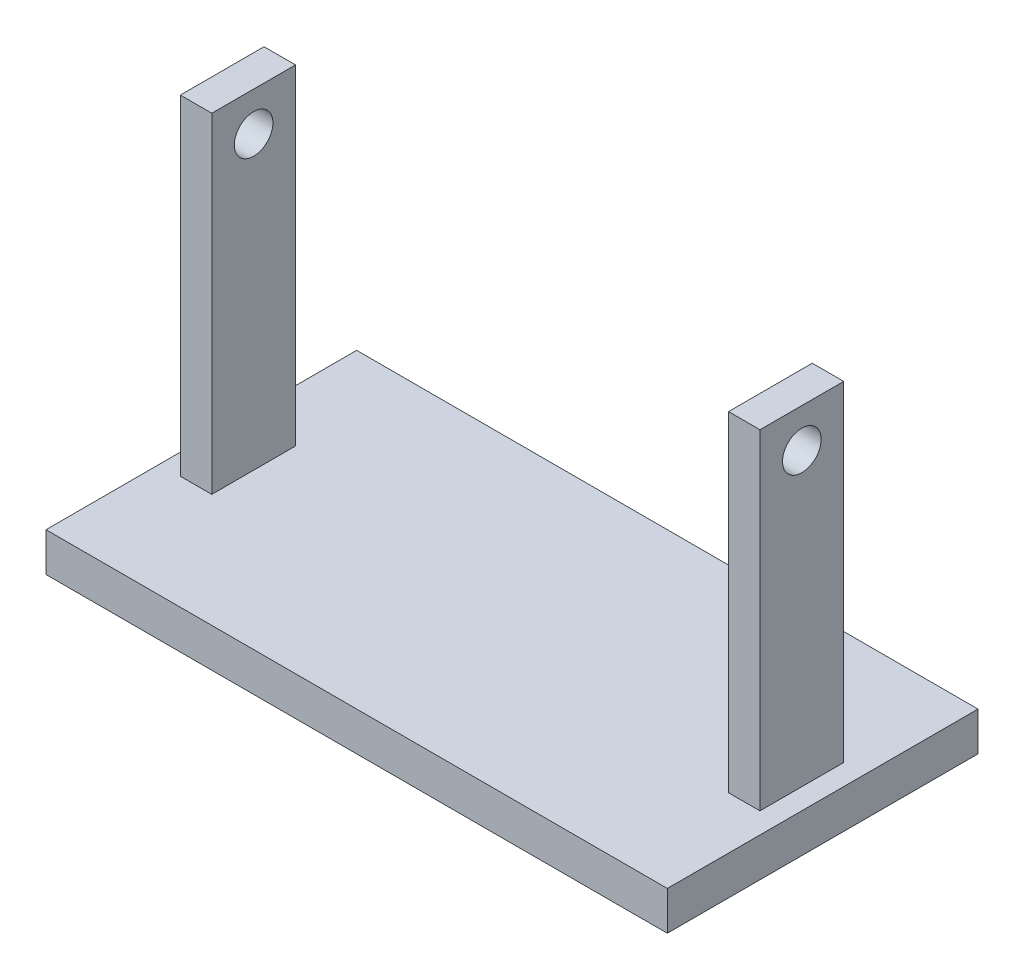
from build123d import *

# Parameters (mm, degrees)
SKETCH1_W             = 8.098713366
SKETCH1_H             = 21.564091284
BOSS_EXTRUDE2_DEPTH   = 95
BOSS_EXTRUDE2_2_DEPTH = 95
SKETCH1_5_W           = 160
SKETCH1_5_H           = 80
SKETCH1_5_W_2         = 8.098713366
SKETCH1_5_H_2         = 21.564091284
BOSS_EXTRUDE3_DEPTH   = 10
SKETCH3_R             = 4.973174901
CUT_EXTRUDE1_DEPTH    = 186.838302856


with BuildPart() as part:
    # Sketch1 → Boss-Extrude2 (new body)
    with BuildSketch(Plane(origin=(0, 0, 0), x_dir=(1, 0, 0), z_dir=(0, 1, 0))):
        with Locations((-70.582059298, 0)):
            Rectangle(SKETCH1_W, SKETCH1_H)
    extrude(amount=BOSS_EXTRUDE2_DEPTH)



with BuildPart() as body_2:
    # Sketch1 → Boss-Extrude2 2 (new body)
    with BuildSketch(Plane(origin=(0, 0, 0), x_dir=(1, 0, 0), z_dir=(0, 1, 0))):
        with Locations((70.582059298, 0)):
            Rectangle(SKETCH1_W, SKETCH1_H)
    extrude(amount=BOSS_EXTRUDE2_2_DEPTH)


with BuildPart() as part_1:
    add(part.part)

    add(body_2.part)  # Boss-Extrude3 merges body 2
    # Sketch1_5 → Boss-Extrude3 (add)
    with BuildSketch(Plane(origin=(0, 0, 0), x_dir=(1, 0, 0), z_dir=(0, 1, 0))):
        Rectangle(SKETCH1_5_W, SKETCH1_5_H)
        with Locations((-70.582059298, 0)):
            Rectangle(SKETCH1_5_W_2, SKETCH1_5_H_2, mode=Mode.SUBTRACT)
        with Locations((70.582059298, 0)):
            Rectangle(SKETCH1_5_W_2, SKETCH1_5_H_2, mode=Mode.SUBTRACT)
    extrude(amount=BOSS_EXTRUDE3_DEPTH)

    # Sketch3 → Cut-Extrude1 (cut, through all)
    with BuildSketch(Plane(origin=(74.631415981, 0, 0), x_dir=(0, 0, -1), z_dir=(1, 0, 0))):
        with Locations((0, 85)):
            Circle(SKETCH3_R)
    extrude(amount=-CUT_EXTRUDE1_DEPTH, mode=Mode.SUBTRACT)


solid = part_1.part
